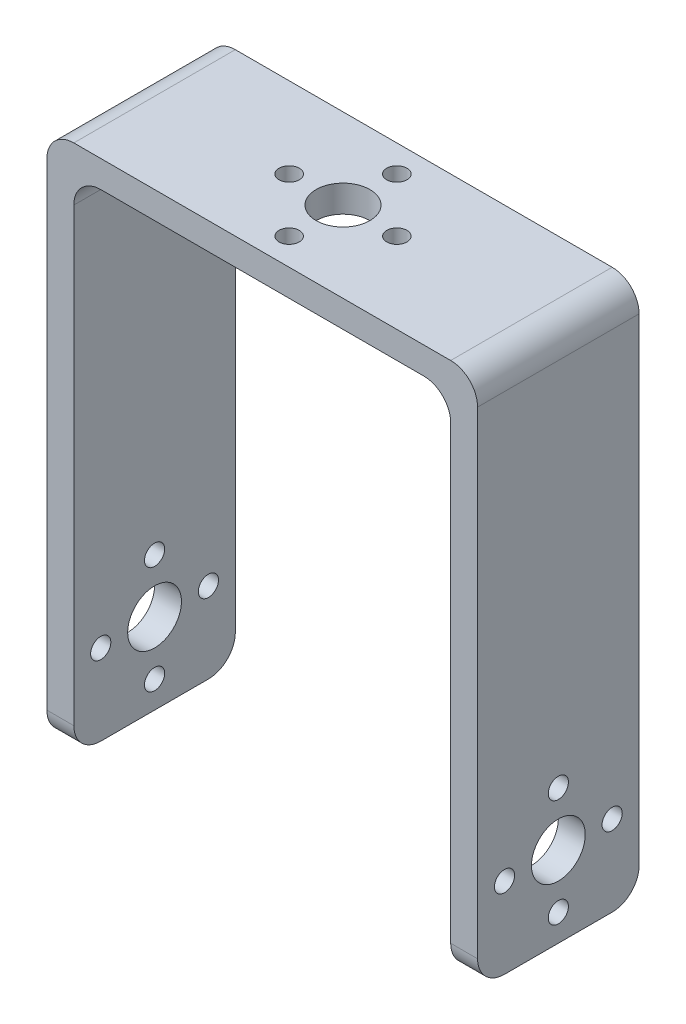
from build123d import *

# Parameters (mm, degrees)
BOSS_EXTRUDE1_DEPTH = 24
SKETCH2_R           = 4
SKETCH2_R_2         = 1.5
CUT_EXTRUDE1_DEPTH  = 4
SKETCH3_R           = 4
SKETCH3_R_2         = 1.5
CUT_EXTRUDE2_DEPTH  = 4
FILLET1_R           = 4
SKETCH6_R           = 4
SKETCH6_R_2         = 1.5
CUT_EXTRUDE3_DEPTH  = 4


with BuildPart() as part:
    # Sketch1 → Boss-Extrude1 (new body)
    with BuildSketch(Plane.XY):
        Polygon((-35.947712149, -38.738038278), (-35.947712149, 36.261961722), (20.052287851, 36.261961722), (20.052287851, -38.738038278), (24.052287851, -38.738038278), (24.052287851, 40.261961722), (-39.947712149, 40.261961722), (-39.947712149, -38.738038278), align=None)
    extrude(amount=BOSS_EXTRUDE1_DEPTH)

    # Sketch2 → Cut-Extrude1 (cut)
    with BuildSketch(Plane(origin=(24.052287851, 0, 0), x_dir=(0, 0, -1), z_dir=(1, 0, 0))):
        with Locations((-12, -26.738038278)):
            Circle(SKETCH2_R)
        with Locations((-4, -26.738038278)):
            Circle(SKETCH2_R_2)
        with Locations((-12, -34.738038278)):
            Circle(SKETCH2_R_2)
        with Locations((-20, -26.738038278)):
            Circle(SKETCH2_R_2)
        with Locations((-12, -18.738038278)):
            Circle(SKETCH2_R_2)
    extrude(amount=-CUT_EXTRUDE1_DEPTH, mode=Mode.SUBTRACT)

    # Sketch3 → Cut-Extrude2 (cut)
    with BuildSketch(Plane.ZY.offset(39.947712149)):
        with Locations((12, -26.738038278)):
            Circle(SKETCH3_R)
        with Locations((20, -26.738038278)):
            Circle(SKETCH3_R_2)
        with Locations((12, -34.738038278)):
            Circle(SKETCH3_R_2)
        with Locations((4, -26.738038278)):
            Circle(SKETCH3_R_2)
        with Locations((12, -18.738038278)):
            Circle(SKETCH3_R_2)
    extrude(amount=-CUT_EXTRUDE2_DEPTH, mode=Mode.SUBTRACT)

    # Fillet1
    fillet1_edges = [part.edges().sort_by_distance(p)[0] for p in [
        (22.052287851, -38.738038278, 0),
        (20.052287851, 36.261961722, 12),
        (-35.947712149, 36.261961722, 12),
        (-39.947712149, 40.261961722, 12),
        (24.052287851, 40.261961722, 12),
        (-37.947712149, -38.738038278, 24),
        (22.052287851, -38.738038278, 24),
        (-37.947712149, -38.738038278, 0),
    ]]
    fillet(fillet1_edges, radius=FILLET1_R)

    # Sketch6 → Cut-Extrude3 (cut)
    with BuildSketch(Plane(origin=(0, 40.261961722, 0), x_dir=(1, 0, 0), z_dir=(0, 1, 0))):
        with Locations((-7.947712149, -12)):
            Circle(SKETCH6_R)
        with Locations((0.052287851, -12)):
            Circle(SKETCH6_R_2)
        with Locations((-7.947712149, -20)):
            Circle(SKETCH6_R_2)
        with Locations((-15.947712149, -12)):
            Circle(SKETCH6_R_2)
        with Locations((-7.947712149, -4)):
            Circle(SKETCH6_R_2)
    extrude(amount=-CUT_EXTRUDE3_DEPTH, mode=Mode.SUBTRACT)


solid = part.part
